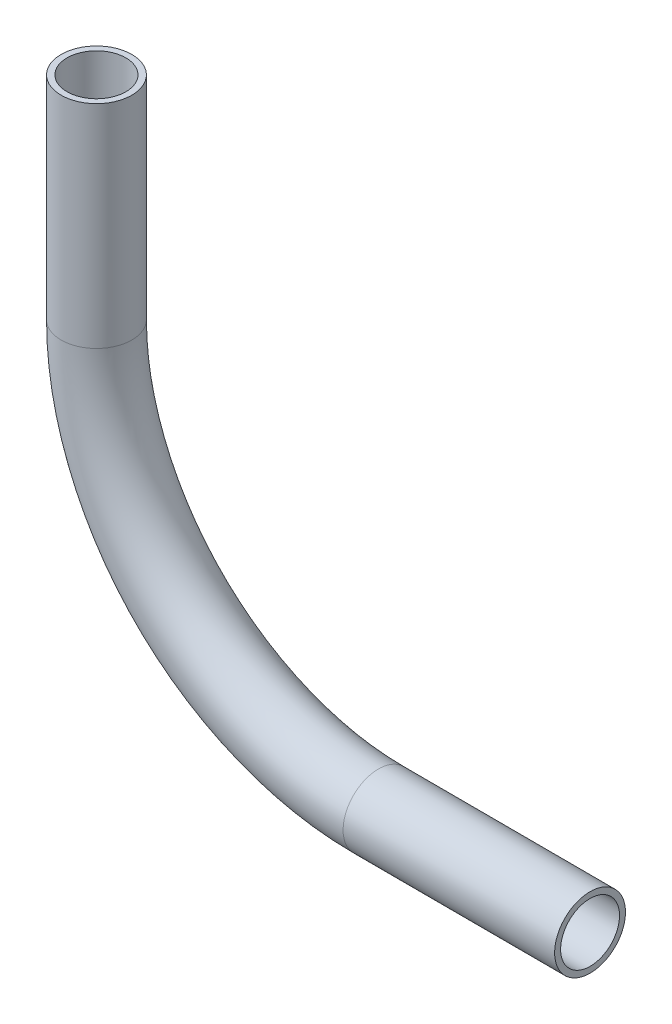
from build123d import *

# Parameters (mm, degrees)
SKETCH1_R                 = 6.35
SKETCH1_R_2               = 5.2832
PIPE_0_5_SCH_40_1_DEPTH   = 38.1
SKETCH1_ON_SEGMENT_2_R    = 6.35
SKETCH1_ON_SEGMENT_2_R_2  = 5.2832
PIPE_0_5_SCH_40_1_2_ANGLE = 90
SKETCH1_ON_SEGMENT_3_R    = 6.35
SKETCH1_ON_SEGMENT_3_R_2  = 5.2832
PIPE_0_5_SCH_40_1_3_DEPTH = 38.1


with BuildPart() as part:
    # Sketch1 → Pipe 0.5 SCH 40(1) (new body)
    with BuildSketch(Plane(origin=(44.524118781, -623.116394341, 354.927728694), x_dir=(1, 0, 0), z_dir=(0, -1, 0))):
        Circle(SKETCH1_R)
        Circle(SKETCH1_R_2, mode=Mode.SUBTRACT)
    extrude(amount=PIPE_0_5_SCH_40_1_DEPTH)


with BuildPart() as body_2:
    # Sketch1 on segment 2 (carried to the start of arc 2) → Pipe 0.5 SCH 40_1 2 (revolve)
    with BuildSketch(Plane(origin=(44.524118781, -661.216394341, 354.927728694), x_dir=(1, 0, 0), z_dir=(0, -1, 0))):
        Circle(SKETCH1_ON_SEGMENT_2_R)
        Circle(SKETCH1_ON_SEGMENT_2_R_2, mode=Mode.SUBTRACT)
    revolve(axis=Axis((95.323978696, -661.216394341, 355.047029303), (-0.002348437, 0, 0.999997242)), revolution_arc=PIPE_0_5_SCH_40_1_2_ANGLE)


with BuildPart() as body_3:
    # Sketch1 on segment 3 (carried to segment 3) → Pipe 0.5 SCH 40_1 3 (new body)
    with BuildSketch(Plane(origin=(95.323978696, -712.016394341, 355.047029303), x_dir=(5.515e-06, 0.999997242, -0.002348431), z_dir=(0.999997242, 0, 0.002348437))):
        Circle(SKETCH1_ON_SEGMENT_3_R)
        Circle(SKETCH1_ON_SEGMENT_3_R_2, mode=Mode.SUBTRACT)
    extrude(amount=PIPE_0_5_SCH_40_1_3_DEPTH)


with BuildPart() as part_1:
    add(part.part)

    # Pipe 0.5 SCH 40(1) as one body: union body 2, body 3
    add(body_2.part)
    add(body_3.part)


solid = part_1.part
